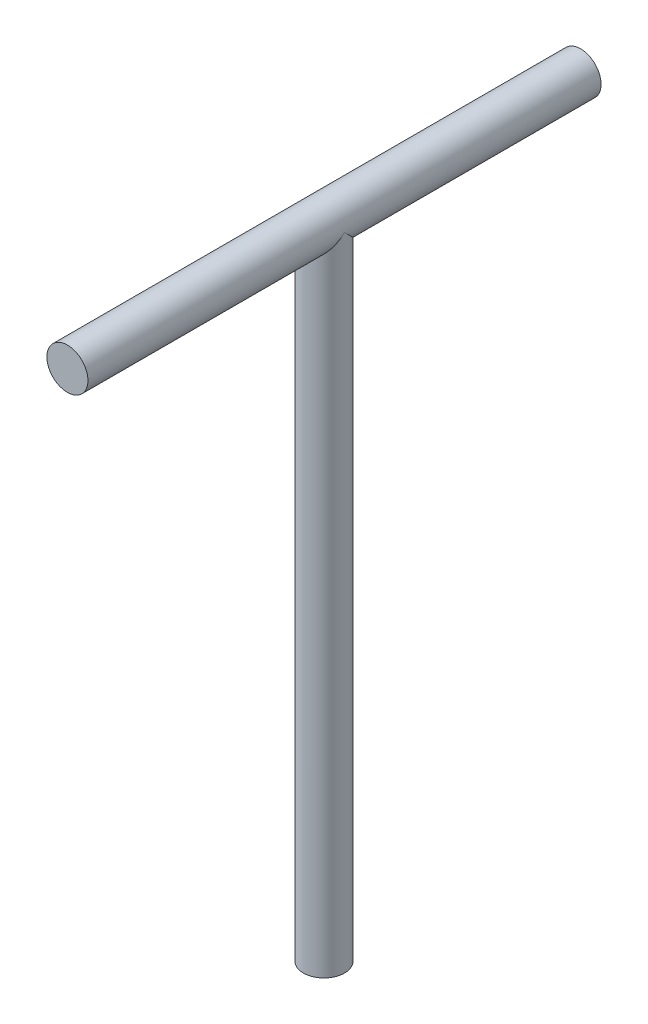
from build123d import *

# Parameters (mm, degrees)
SKETCH1_R           = 16
BOSS_EXTRUDE1_DEPTH = 200
SKETCH3_R           = 16
BOSS_EXTRUDE2_DEPTH = 500


with BuildPart() as part:
    # Sketch1 → Boss-Extrude1 (new body, symmetric)
    with BuildSketch(Plane.XY):
        Circle(SKETCH1_R)
    extrude(amount=BOSS_EXTRUDE1_DEPTH, both=True)

    # Sketch3 → Boss-Extrude2 (add)
    with BuildSketch(Plane(origin=(0, 0, 0), x_dir=(1, 0, 0), z_dir=(0, 1, 0))):
        Circle(SKETCH3_R)
    extrude(amount=-BOSS_EXTRUDE2_DEPTH)


solid = part.part
